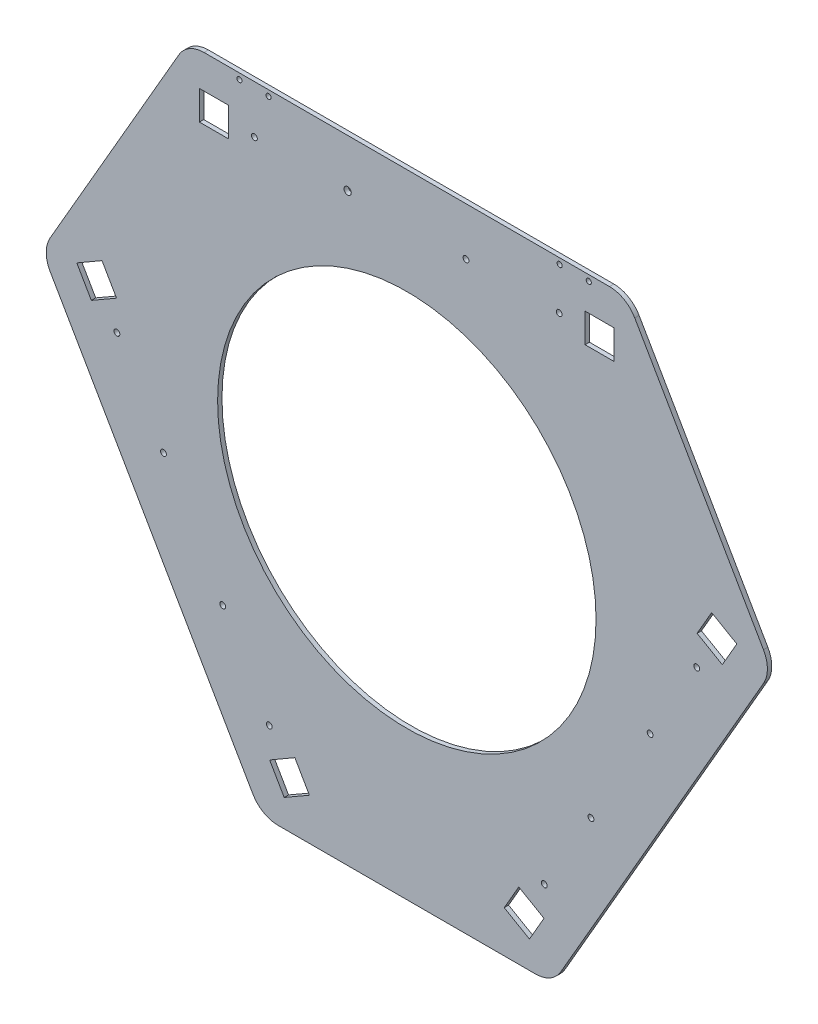
from build123d import *

# Parameters (mm, degrees)
SKETCH_1_R          = 130
SKETCH_1_R_2        = 2
SKETCH_1_R_3        = 2.5
SKETCH_1_R_4        = 1.75
EXTRUDE_1_DEPTH     = 3
SKETCH_8_W          = 20
SKETCH_8_H          = 20
CUT_EXTRUDE_4_DEPTH = 4
FILLET_2_R          = 20


with BuildPart() as part:
    # 草图1 → 凸台-拉伸1 (new body)
    with BuildSketch(Plane.XY):
        Polygon((150.828607906, 202.550991214), (-150.828607906, 202.550991214), (-250.828607906, 29.345910457), (-100, -231.89690167), (100, -231.89690167), (250.828607906, 29.345910457), align=None)
        Circle(SKETCH_1_R, mode=Mode.SUBTRACT)
        with Locations((-199.191349288, 5.907554968)):
            Circle(SKETCH_1_R_2, mode=Mode.SUBTRACT)
        with Locations((-167.168935942, -49.556891928)):
            Circle(SKETCH_1_R_2, mode=Mode.SUBTRACT)
        with Locations((-126.501995314, -119.994099285)):
            Circle(SKETCH_1_R_2, mode=Mode.SUBTRACT)
        with Locations((-94.479581967, -175.458546182)):
            Circle(SKETCH_1_R_2, mode=Mode.SUBTRACT)
        with Locations((199.191349288, 5.907554968)):
            Circle(SKETCH_1_R_2, mode=Mode.SUBTRACT)
        with Locations((167.168935942, -49.556891928)):
            Circle(SKETCH_1_R_2, mode=Mode.SUBTRACT)
        with Locations((126.501995313, -119.994099286)):
            Circle(SKETCH_1_R_2, mode=Mode.SUBTRACT)
        with Locations((94.479581967, -175.458546182)):
            Circle(SKETCH_1_R_2, mode=Mode.SUBTRACT)
        with Locations((104.711767321, 169.550991214)):
            Circle(SKETCH_1_R_2, mode=Mode.SUBTRACT)
        with Locations((40.666940629, 169.550991214)):
            Circle(SKETCH_1_R_2, mode=Mode.SUBTRACT)
        with Locations((-40.666940629, 169.550991214)):
            Circle(SKETCH_1_R_3, mode=Mode.SUBTRACT)
        with Locations((-104.711767321, 169.550991214)):
            Circle(SKETCH_1_R_2, mode=Mode.SUBTRACT)
        with Locations((125, 198.550991214)):
            Circle(SKETCH_1_R_4, mode=Mode.SUBTRACT)
        with Locations((105, 198.550991214)):
            Circle(SKETCH_1_R_4, mode=Mode.SUBTRACT)
        with Locations((-95, 198.550991214)):
            Circle(SKETCH_1_R_4, mode=Mode.SUBTRACT)
        with Locations((-115, 198.550991214)):
            Circle(SKETCH_1_R_4, mode=Mode.SUBTRACT)
    extrude(amount=EXTRUDE_1_DEPTH)

    # 草图8 → 切除-拉伸4 (cut, through all)
    with BuildSketch(Plane.XY.offset(3)):
        with Locations((-132.5, 169.550991214)):
            Rectangle(SKETCH_8_W, SKETCH_8_H)
        Polygon((-209.42521159, 43.633124432), (-226.745719666, 33.633124432), (-216.745719666, 16.312616357), (-199.42521159, 26.312616357), align=None)
        Polygon((-84.245719666, -213.184115646), (-66.92521159, -203.184115646), (-76.92521159, -185.86360757), (-94.245719666, -195.86360757), align=None)
        Polygon((66.92521159, -203.184115646), (84.245719666, -213.184115646), (94.245719666, -195.86360757), (76.92521159, -185.86360757), align=None)
        Polygon((209.42521159, 43.633124432), (199.42521159, 26.312616357), (216.745719666, 16.312616357), (226.745719666, 33.633124432), align=None)
        with Locations((132.5, 169.550991214)):
            Rectangle(SKETCH_8_W, SKETCH_8_H)
    extrude(amount=-CUT_EXTRUDE_4_DEPTH, mode=Mode.SUBTRACT)

    # 圆角2
    fillet_2_edges = [part.edges().sort_by_distance(p)[0] for p in [
        (-150.828607906, 202.550991214, 1.5),
        (150.828607906, 202.550991214, 1.5),
        (250.828607906, 29.345910457, 1.5),
        (100, -231.89690167, 1.5),
        (-100, -231.89690167, 1.5),
        (-250.828607906, 29.345910457, 1.5),
    ]]
    fillet(fillet_2_edges, radius=FILLET_2_R)


solid = part.part
